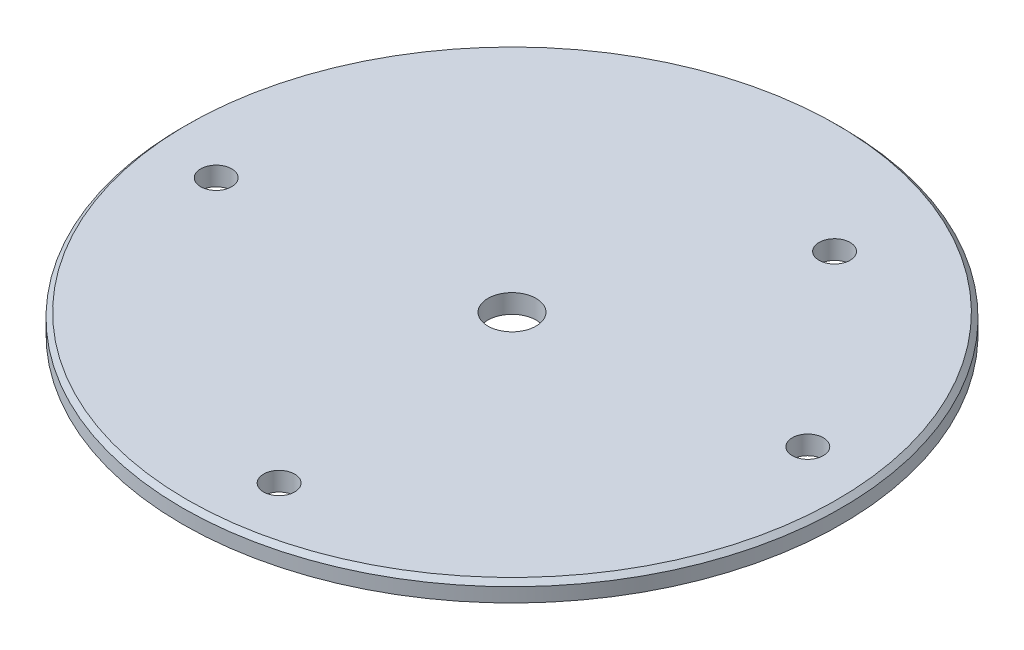
from build123d import *

# Parameters (mm, degrees)
SKETCH1_R             = 35.015
SKETCH1_R_2           = 2.555
BOSS_EXTRUDE1_DEPTH   = 2
CHAMFER1_SIZE         = 0.5
M4X0_7_TAPPED_HOLE1_D = 3.3


with BuildPart() as part:
    # Sketch1 → Boss-Extrude1 (new body)
    with BuildSketch(Plane(origin=(0, 0, 0), x_dir=(1, 0, 0), z_dir=(0, 1, 0))):
        Circle(SKETCH1_R)
        Circle(SKETCH1_R_2, mode=Mode.SUBTRACT)
    extrude(amount=BOSS_EXTRUDE1_DEPTH)

    # Chamfer1
    chamfer1_edges = [part.edges().sort_by_distance(p)[0] for p in [
        (-35.015, 2, 0),
    ]]
    chamfer(chamfer1_edges, length=CHAMFER1_SIZE)

    # M4x0.7 Tapped Hole1 (through all)
    with Locations(Plane(origin=(3.342611255, 2, 28.08606327), x_dir=(0, 0, 1), z_dir=(0, 1, 0))):
        with Locations((0, 0), (-24.743452015, -31.428674525), (-50.82191635, 8.193461939), (-31.428674525, 24.743452015)):
            Hole(M4X0_7_TAPPED_HOLE1_D / 2)


solid = part.part
